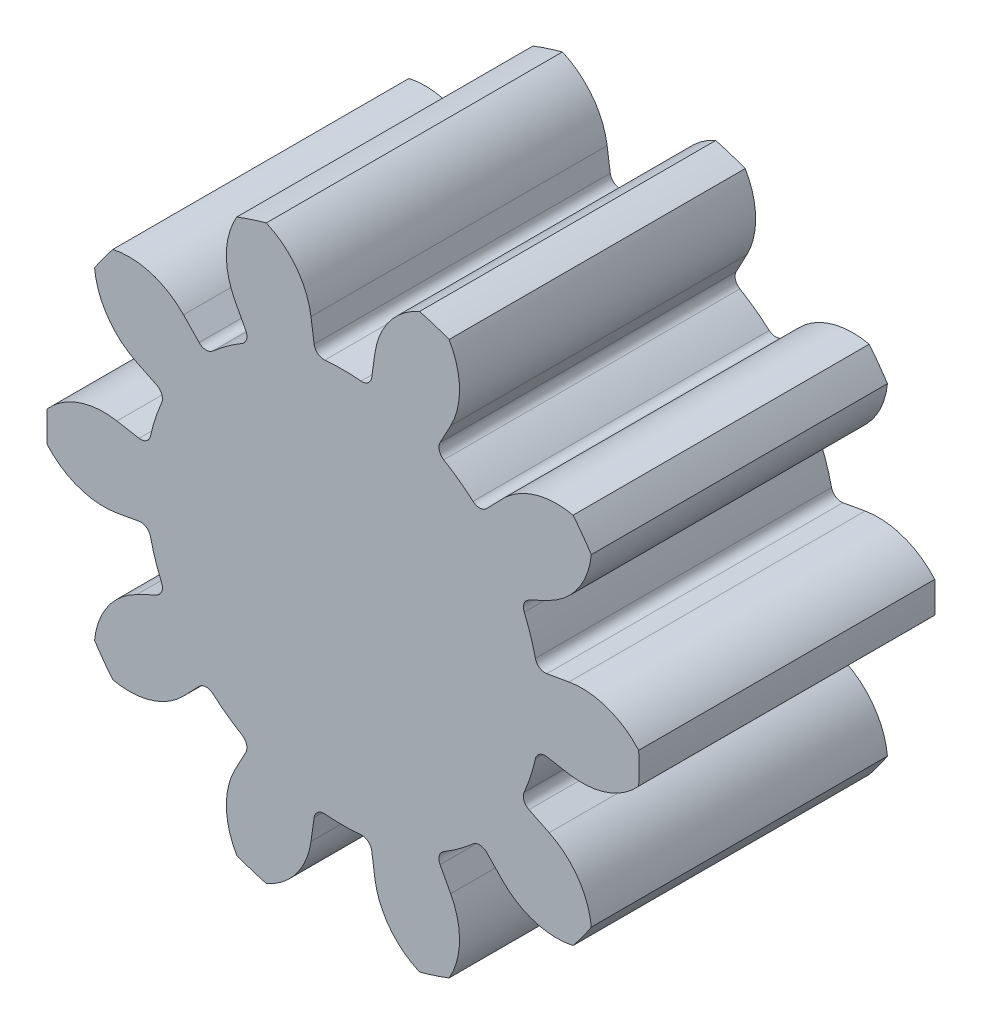
from build123d import *

# Parameters (mm, degrees)
BOSS_EXTRUDE1_DEPTH      = 6
FILLET3_R                = 0.2
FILLET4_R                = 0.2
CIRPATTERN1_COUNT        = 10
FILLET3_OF_CIRPATTERN1_R = 0.2
FILLET4_OF_CIRPATTERN1_R = 0.2


with BuildPart() as part:
    # Sketch1 → Boss-Extrude1 (new body)
    with BuildSketch(Plane.XY):
        with BuildLine():
            Line((0, 0), (3.80266937, -1.235562177))
            ThreePointArc((3.80266937, -1.235562177), (3.87959472, -0.967291603), (3.937619073, -0.694308482))
            Line((3.937619073, -0.694308482), (4.579356052, -0.807464026))
            ThreePointArc((4.579356052, -0.807464026), (5.349965783, -0.745072725), (5.991777209, -0.314015737))
            ThreePointArc((5.991777209, -0.314015737), (6, 0), (5.991777209, 0.314015737))
            ThreePointArc((5.991777209, 0.314015737), (5.349965783, 0.745072725), (4.579356052, 0.807464026))
            Line((4.579356052, 0.807464026), (3.937619073, 0.694308482))
            ThreePointArc((3.937619073, 0.694308482), (3.87959472, 0.967291603), (3.80266937, 1.235562177))
            Line((3.80266937, 1.235562177), (0, 0))
        make_face()
    boss_extrude1 = extrude(amount=BOSS_EXTRUDE1_DEPTH)

    # Fillet3
    fillet3_edges = [part.edges().sort_by_distance(p)[0] for p in [
        (3.937619073, 0.694308482, 3),
    ]]
    fillet(fillet3_edges, radius=FILLET3_R)

    # Fillet4
    fillet4_edges = [part.edges().sort_by_distance(p)[0] for p in [
        (3.937619073, -0.694308482, 3),
    ]]
    fillet(fillet4_edges, radius=FILLET4_R)

    # CirPattern1: Boss-Extrude1 ×10 about axis
    cirpattern1_axis = Axis((0, 0, 0), (0, 0, 1))
    for i in range(1, CIRPATTERN1_COUNT):
        add(boss_extrude1.rotate(cirpattern1_axis, i * 360 / CIRPATTERN1_COUNT))

    # Fillet3 of CirPattern1
    fillet3_of_cirpattern1_edges = [part.edges().sort_by_distance(p)[0] for p in [
        (2.777496461, 2.876181782, 3),
        (0.556464605, 3.959451399, 3),
        (-1.877117817, 3.530345158, 3),
        (-3.593705034, 1.752767059, 3),
        (-3.937619073, -0.694308482, 3),
        (-2.777496461, -2.876181782, 3),
        (-0.556464605, -3.959451399, 3),
        (1.877117817, -3.530345158, 3),
        (3.593705034, -1.752767059, 3),
    ]]
    fillet(fillet3_of_cirpattern1_edges, radius=FILLET3_OF_CIRPATTERN1_R)

    # Fillet4 of CirPattern1
    fillet4_of_cirpattern1_edges = [part.edges().sort_by_distance(p)[0] for p in [
        (3.593705034, 1.752767059, 3),
        (1.877117817, 3.530345158, 3),
        (-0.556464605, 3.959451399, 3),
        (-2.777496461, 2.876181782, 3),
        (-3.937619073, 0.694308482, 3),
        (-3.593705034, -1.752767059, 3),
        (-1.877117817, -3.530345158, 3),
        (0.556464605, -3.959451399, 3),
        (2.777496461, -2.876181782, 3),
    ]]
    fillet(fillet4_of_cirpattern1_edges, radius=FILLET4_OF_CIRPATTERN1_R)


solid = part.part
